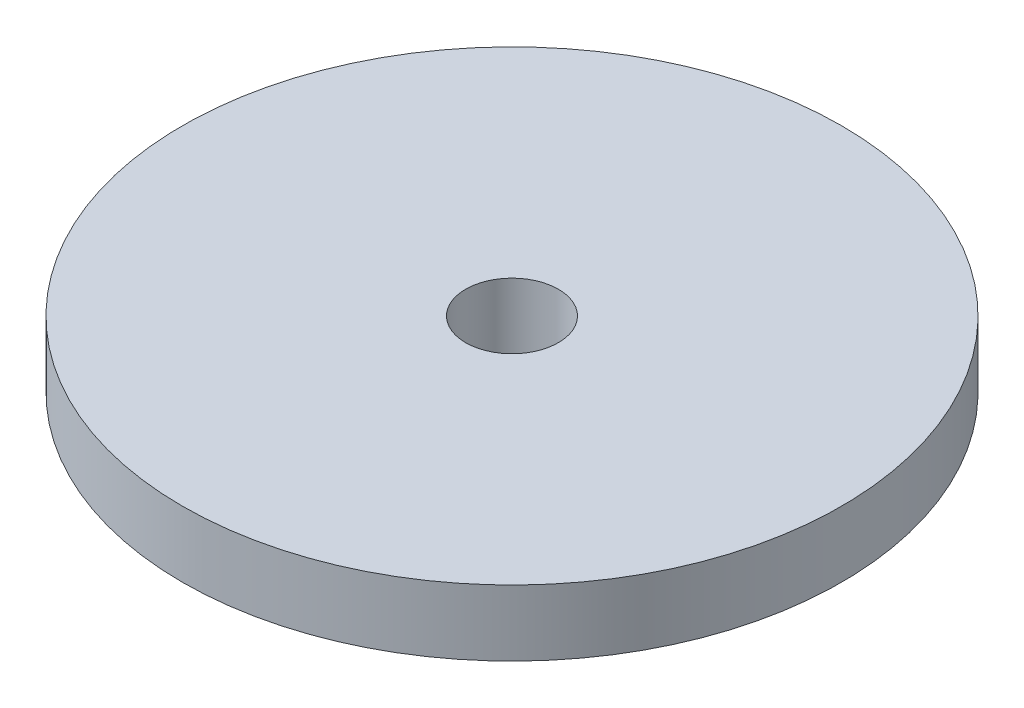
from build123d import *

# Parameters (mm, degrees)
SKETCH1_R           = 12.7
SKETCH1_R_2         = 1.7859375
BOSS_EXTRUDE1_DEPTH = 2.54


with BuildPart() as part:
    # Sketch1 → Boss-Extrude1 (new body)
    with BuildSketch(Plane(origin=(0, 0, 0), x_dir=(1, 0, 0), z_dir=(0, 1, 0))):
        Circle(SKETCH1_R)
        Circle(SKETCH1_R_2, mode=Mode.SUBTRACT)
    extrude(amount=BOSS_EXTRUDE1_DEPTH)


solid = part.part
